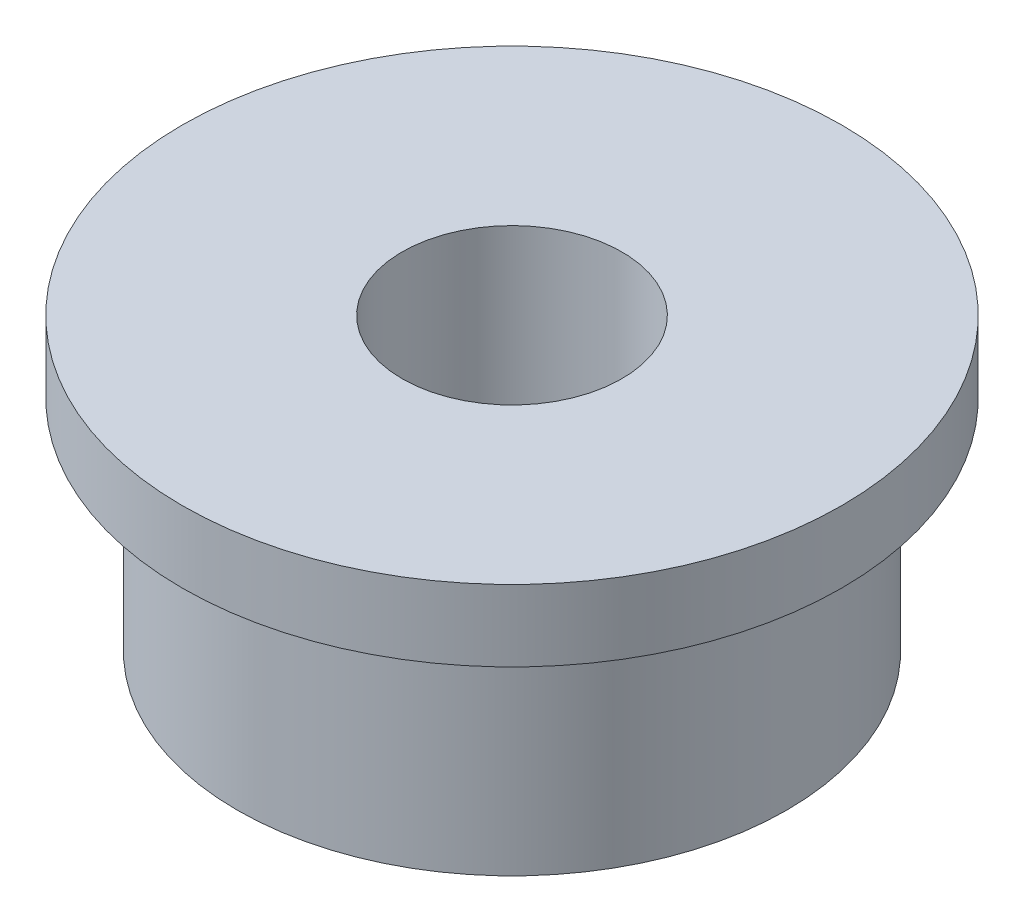
from build123d import *

# Parameters (mm, degrees)
SKETCH1_R           = 2.5
SKETCH1_R_2         = 1
BOSS_EXTRUDE1_DEPTH = 2
SKETCH2_R           = 3
SKETCH2_R_2         = 1
BOSS_EXTRUDE2_DEPTH = 0.65


with BuildPart() as part:
    # Sketch1 → Boss-Extrude1 (new body)
    with BuildSketch(Plane(origin=(0, 0, 0), x_dir=(1, 0, 0), z_dir=(0, 1, 0))):
        Circle(SKETCH1_R)
        Circle(SKETCH1_R_2, mode=Mode.SUBTRACT)
    extrude(amount=BOSS_EXTRUDE1_DEPTH)

    # Sketch2 → Boss-Extrude2 (add)
    with BuildSketch(Plane(origin=(0, 2, 0), x_dir=(1, 0, 0), z_dir=(0, 1, 0))):
        Circle(SKETCH2_R)
        Circle(SKETCH2_R_2, mode=Mode.SUBTRACT)
    extrude(amount=BOSS_EXTRUDE2_DEPTH)


solid = part.part
